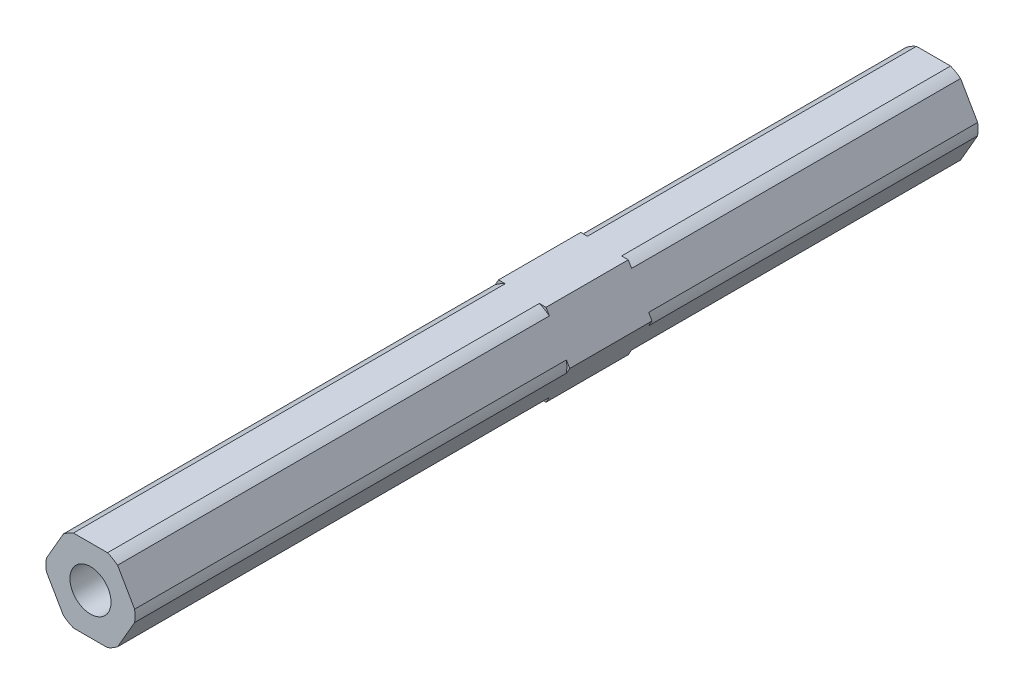
from build123d import *

# Parameters (mm, degrees)
BOSS_EXTRUDE1_DEPTH = 12.7
BOSS_EXTRUDE2_DEPTH = 66.675
BOSS_EXTRUDE3_DEPTH = 50.8
SKETCH5_R           = 3.175
CUT_EXTRUDE1_DEPTH  = 7.62


with BuildPart() as part:
    # Sketch1 → Boss-Extrude1 (new body)
    with BuildSketch(Plane.XY):
        Polygon((3.666174209, -6.35), (7.332348419, 0), (3.666174209, 6.35), (-3.666174209, 6.35), (-7.332348419, 0), (-3.666174209, -6.35), align=None)
    extrude(amount=BOSS_EXTRUDE1_DEPTH)

    # Sketch2 → Boss-Extrude2 (add)
    with BuildSketch(Plane.XY.offset(12.7)):
        with BuildLine():
            Line((-6.816751826, -0.893039494), (-4.181770802, -5.456960506))
            ThreePointArc((-4.181770802, -5.456960506), (-3.4375, -5.953924651), (-2.634981025, -6.35))
            Line((-2.634981025, -6.35), (2.634981025, -6.35))
            ThreePointArc((2.634981025, -6.35), (3.4375, -5.953924651), (4.181770802, -5.456960506))
            Line((4.181770802, -5.456960506), (6.816751826, -0.893039494))
            ThreePointArc((6.816751826, -0.893039494), (6.875, 0), (6.816751826, 0.893039494))
            Line((6.816751826, 0.893039494), (4.181770802, 5.456960506))
            ThreePointArc((4.181770802, 5.456960506), (3.4375, 5.953924651), (2.634981025, 6.35))
            Line((2.634981025, 6.35), (-2.634981025, 6.35))
            ThreePointArc((-2.634981025, 6.35), (-3.4375, 5.953924651), (-4.181770802, 5.456960506))
            Line((-4.181770802, 5.456960506), (-6.816751826, 0.893039494))
            ThreePointArc((-6.816751826, 0.893039494), (-6.875, 0), (-6.816751826, -0.893039494))
        make_face()
    extrude(amount=BOSS_EXTRUDE2_DEPTH)

    # Sketch3 → Boss-Extrude3 (add)
    with BuildSketch(Plane(origin=(0, 0, 0), x_dir=(-1, 0, 0), z_dir=(0, 0, -1))):
        with BuildLine():
            Line((-4.181770802, -5.456960506), (-6.816751826, -0.893039494))
            ThreePointArc((-6.816751826, -0.893039494), (-6.875, 0), (-6.816751826, 0.893039494))
            Line((-6.816751826, 0.893039494), (-4.181770802, 5.456960506))
            ThreePointArc((-4.181770802, 5.456960506), (-3.4375, 5.953924651), (-2.634981025, 6.35))
            Line((-2.634981025, 6.35), (2.634981025, 6.35))
            ThreePointArc((2.634981025, 6.35), (3.4375, 5.953924651), (4.181770802, 5.456960506))
            Line((4.181770802, 5.456960506), (6.816751826, 0.893039494))
            ThreePointArc((6.816751826, 0.893039494), (6.875, 0), (6.816751826, -0.893039494))
            Line((6.816751826, -0.893039494), (4.181770802, -5.456960506))
            ThreePointArc((4.181770802, -5.456960506), (3.4375, -5.953924651), (2.634981025, -6.35))
            Line((2.634981025, -6.35), (-2.634981025, -6.35))
            ThreePointArc((-2.634981025, -6.35), (-3.4375, -5.953924651), (-4.181770802, -5.456960506))
        make_face()
    extrude(amount=BOSS_EXTRUDE3_DEPTH)

    # Sketch5 → Cut-Extrude1 (cut)
    with BuildSketch(Plane.XY.offset(79.375)):
        Circle(SKETCH5_R)
    extrude(amount=-CUT_EXTRUDE1_DEPTH, mode=Mode.SUBTRACT)


solid = part.part
